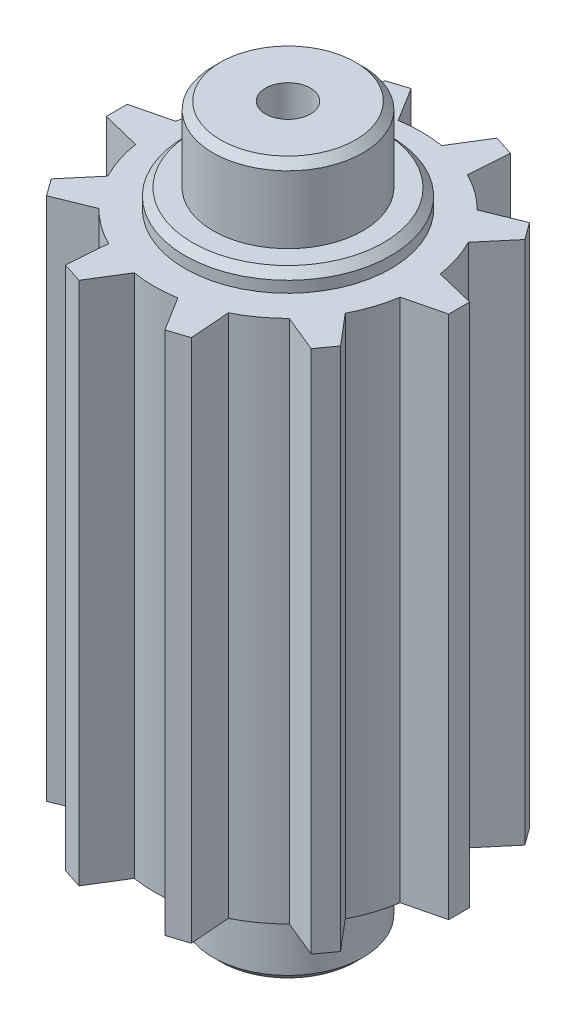
from build123d import *

# Parameters (mm, degrees)
BOSS_EXTRUDE3_DEPTH = 14
CIRPATTERN2_COUNT   = 10
SKETCH3_R           = 2.75
BOSS_EXTRUDE4_DEPTH = 0.5
SKETCH4_R           = 2.75
BOSS_EXTRUDE5_DEPTH = 0.5
SKETCH5_R           = 2
BOSS_EXTRUDE6_DEPTH = 2
SKETCH6_R           = 2
BOSS_EXTRUDE7_DEPTH = 2
CHAMFER1_SIZE       = 0.2
SKETCH7_R           = 0.6
CUT_EXTRUDE1_DEPTH  = 20


with BuildPart() as part:
    # Sketch1 → Boss-Extrude3 (new body)
    with BuildSketch(Plane(origin=(0, 0, 0), x_dir=(1, 0, 0), z_dir=(0, 1, 0))):
        with BuildLine():
            ThreePointArc((3.529675716, 0.535060126), (-3.57, 0), (3.529675716, -0.535060126))
            Line((3.529675716, -0.535060126), (3.265358075, -0.599863853))
            ThreePointArc((3.265358075, -0.599863853), (3.32, 0), (3.265358075, 0.599863853))
            Line((3.265358075, 0.599863853), (3.529675716, 0.535060126))
        make_face()
        with BuildLine():
            Line((3.265358075, -0.599863853), (3.529675716, -0.535060126))
            ThreePointArc((3.529675716, -0.535060126), (3.559904655, -0.268288737), (3.57, 0))
            ThreePointArc((3.57, 0), (3.559904655, 0.268288737), (3.529675716, 0.535060126))
            Line((3.529675716, 0.535060126), (3.265358075, 0.599863853))
            ThreePointArc((3.265358075, 0.599863853), (3.32, 0), (3.265358075, -0.599863853))
        make_face()
        with BuildLine():
            Line((4.57, -0.28), (4.57, 0))
            Line((4.57, 0), (4.57, 0.28))
            Line((4.57, 0.28), (3.529675716, 0.535060126))
            ThreePointArc((3.529675716, 0.535060126), (3.559904655, 0.268288737), (3.57, 0))
            ThreePointArc((3.57, 0), (3.559904655, -0.268288737), (3.529675716, -0.535060126))
            Line((3.529675716, -0.535060126), (4.57, -0.28))
        make_face()
    boss_extrude3 = extrude(amount=BOSS_EXTRUDE3_DEPTH)

    # CirPattern2: Boss-Extrude3 ×10 about axis
    cirpattern2_axis = Axis((0, 0, 0), (0, 1, 0))
    for i in range(1, CIRPATTERN2_COUNT):
        add(boss_extrude3.rotate(cirpattern2_axis, i * 360 / CIRPATTERN2_COUNT))

    # Sketch3 → Boss-Extrude4 (add)
    with BuildSketch(Plane(origin=(0, 14, 0), x_dir=(1, 0, 0), z_dir=(0, 1, 0))):
        Circle(SKETCH3_R)
    extrude(amount=BOSS_EXTRUDE4_DEPTH)

    # Sketch4 → Boss-Extrude5 (add)
    with BuildSketch(Plane.XZ):
        Circle(SKETCH4_R)
    extrude(amount=BOSS_EXTRUDE5_DEPTH)

    # Sketch5 → Boss-Extrude6 (add)
    with BuildSketch(Plane(origin=(0, 14.5, 0), x_dir=(1, 0, 0), z_dir=(0, 1, 0))):
        Circle(SKETCH5_R)
    extrude(amount=BOSS_EXTRUDE6_DEPTH)

    # Sketch6 → Boss-Extrude7 (add)
    with BuildSketch(Plane.XZ.offset(0.5)):
        Circle(SKETCH6_R)
    extrude(amount=BOSS_EXTRUDE7_DEPTH)

    # Chamfer1
    chamfer1_edges = [part.edges().sort_by_distance(p)[0] for p in [
        (-2.75, 14.5, 0),
        (-2.75, -0.5, 0),
        (-2, 16.5, 0),
        (-2, -2.5, 0),
    ]]
    chamfer(chamfer1_edges, length=CHAMFER1_SIZE)

    # Sketch7 → Cut-Extrude1 (cut, through all)
    with BuildSketch(Plane.XZ.offset(2.5)):
        Circle(SKETCH7_R)
    extrude(amount=-CUT_EXTRUDE1_DEPTH, mode=Mode.SUBTRACT)


solid = part.part
